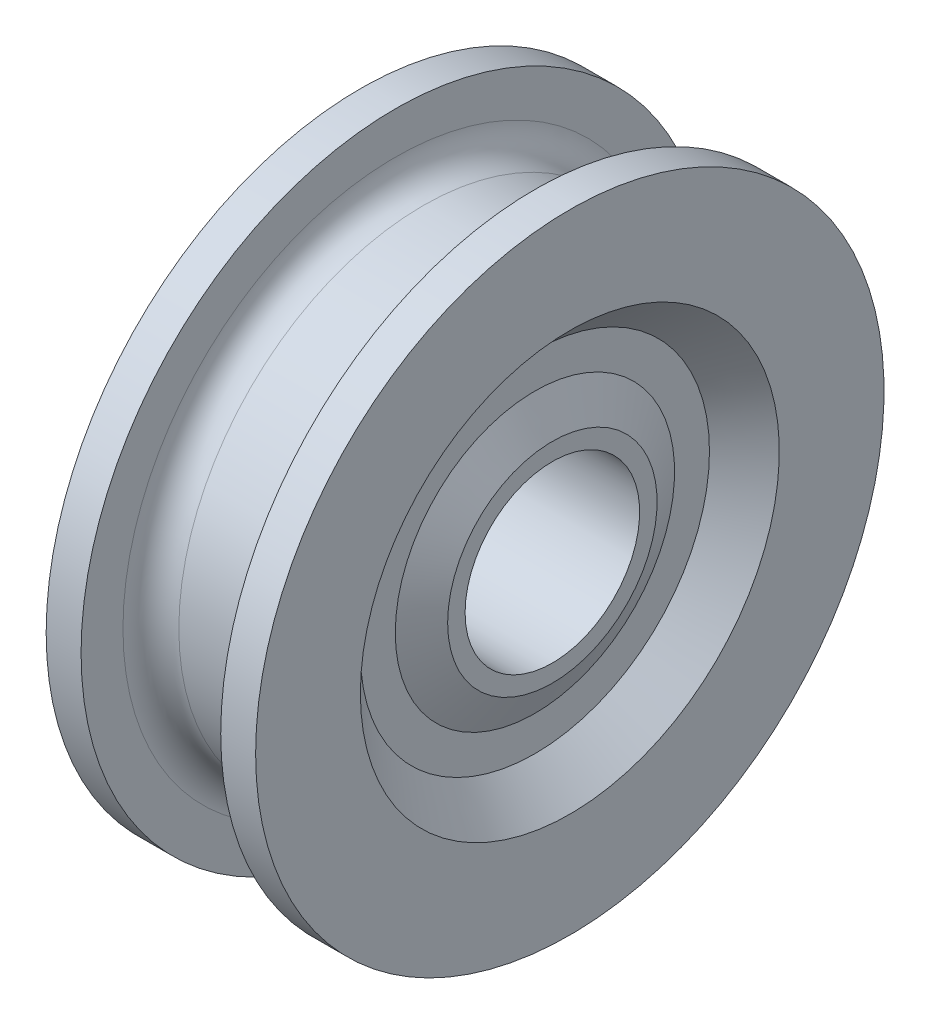
from build123d import *


with BuildPart() as part:
    # Esboço2 → Revolução1 (revolve)
    with BuildSketch(Plane.XY):
        with BuildLine():
            Line((1.25, 6.25), (13.75, 6.25))
            Line((13.75, 6.25), (13.75, 7.5))
            Line((13.75, 7.5), (12.5, 10))
            Line((12.5, 10), (12.5, 12.5))
            Line((12.5, 12.5), (15, 15))
            Line((15, 15), (15, 22.5))
            Line((15, 22.5), (12.5, 22.5))
            Line((12.5, 22.5), (12.5, 19.5))
            ThreePointArc((12.5, 19.5), (11.914213562, 18.085786438), (10.5, 17.5))
            Line((10.5, 17.5), (4.5, 17.5))
            ThreePointArc((4.5, 17.5), (3.085786438, 18.085786438), (2.5, 19.5))
            Line((2.5, 19.5), (2.5, 22.5))
            Line((2.5, 22.5), (0, 22.5))
            Line((0, 22.5), (0, 15))
            Line((0, 15), (2.5, 12.5))
            Line((2.5, 12.5), (2.5, 10))
            Line((2.5, 10), (1.25, 7.5))
            Line((1.25, 7.5), (1.25, 6.25))
        make_face()
    revolve(axis=Axis((0, 0, 0), (1, 0, 0)))


solid = part.part
